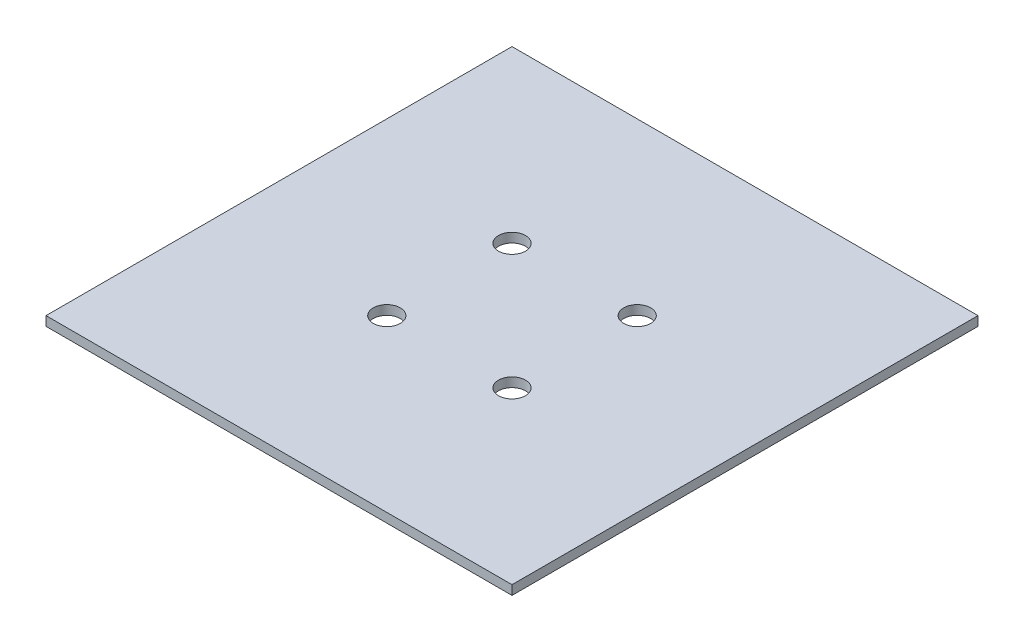
from build123d import *

# Parameters (mm, degrees)
SKETCH_1_W          = 50
SKETCH_1_H          = 50
EXTRUDE_1_DEPTH     = 1
SKETCH_3_R          = 1.45
CUT_EXTRUDE_1_DEPTH = 1


with BuildPart() as part:
    # 草图1 → 凸台-拉伸1 (new body)
    with BuildSketch(Plane(origin=(0, 0, 0), x_dir=(1, 0, 0), z_dir=(0, 1, 0))):
        Rectangle(SKETCH_1_W, SKETCH_1_H)
    extrude(amount=EXTRUDE_1_DEPTH)

    # 草图3 → 切除-拉伸1 (cut)
    with BuildSketch(Plane.XZ):
        with Locations((-6.717514421, -6.717514421)):
            Circle(SKETCH_3_R)
        with Locations((-6.717514421, 6.717514421)):
            Circle(SKETCH_3_R)
        with Locations((6.717514421, 6.717514421)):
            Circle(SKETCH_3_R)
        with Locations((6.717514421, -6.717514421)):
            Circle(SKETCH_3_R)
    extrude(amount=-CUT_EXTRUDE_1_DEPTH, mode=Mode.SUBTRACT)


solid = part.part
